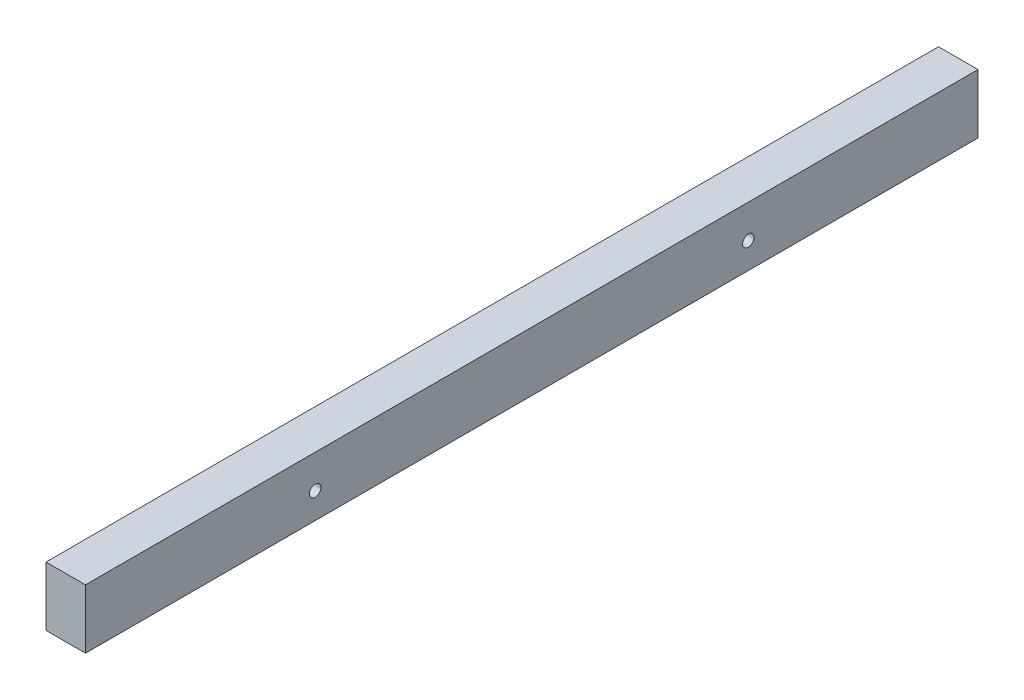
from build123d import *

# Parameters (mm, degrees)
SKETCH1_W           = 12.7
SKETCH1_H           = 19.05
BOSS_EXTRUDE1_DEPTH = 287.02
SKETCH2_R           = 1.85
CUT_EXTRUDE1_DEPTH  = 288.93171569


with BuildPart() as part:
    # Sketch1 → Boss-Extrude1 (new body)
    with BuildSketch(Plane.XY):
        with Locations((6.35, 9.525)):
            Rectangle(SKETCH1_W, SKETCH1_H)
    extrude(amount=BOSS_EXTRUDE1_DEPTH)

    # Sketch2 → Cut-Extrude1 (cut, through all)
    with BuildSketch(Plane(origin=(12.7, 0, 0), x_dir=(0, 0, -1), z_dir=(1, 0, 0))):
        with Locations((-73.853145751, 8.343145751)):
            Circle(SKETCH2_R)
        with Locations((-213.166854249, 8.343145751)):
            Circle(SKETCH2_R)
    extrude(amount=-CUT_EXTRUDE1_DEPTH, mode=Mode.SUBTRACT)


solid = part.part
